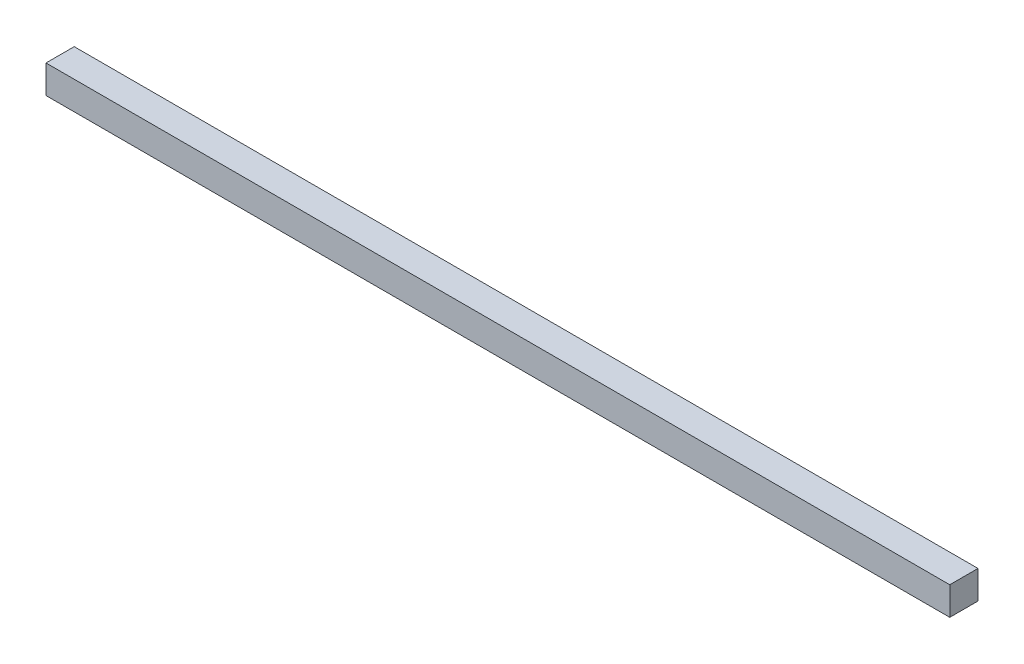
from build123d import *

# Parameters (mm, degrees)
BOSS_EXTRUDE1_DEPTH      = 609.6
BOSS_EXTRUDE1_DEPTH_BACK = 609.6
SKETCH1_W                = 38.1
SKETCH1_H                = 38.1


with BuildPart() as part:
    # Sketch1 → Boss-Extrude1 (new, two sides: drawn at the far end of the back side and taken through both)
    with BuildSketch(Plane(origin=(0, 0, 0), x_dir=(0, 0, -1), z_dir=(1, 0, 0)).offset(-BOSS_EXTRUDE1_DEPTH_BACK)):
        Rectangle(SKETCH1_W, SKETCH1_H)
    extrude(amount=BOSS_EXTRUDE1_DEPTH + BOSS_EXTRUDE1_DEPTH_BACK)


solid = part.part
